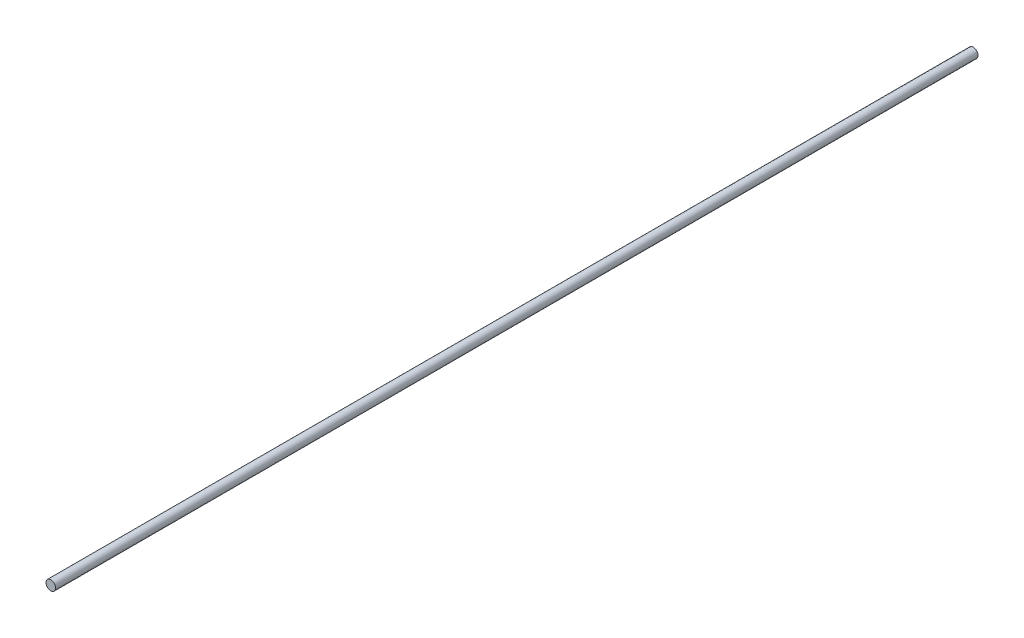
from build123d import *

# Parameters (mm, degrees)
SKETCH1_R           = 10
BOSS_EXTRUDE1_DEPTH = 1920


with BuildPart() as part:
    # Sketch1 → Boss-Extrude1 (new body)
    with BuildSketch(Plane.XY):
        Circle(SKETCH1_R)
    extrude(amount=BOSS_EXTRUDE1_DEPTH)


solid = part.part
